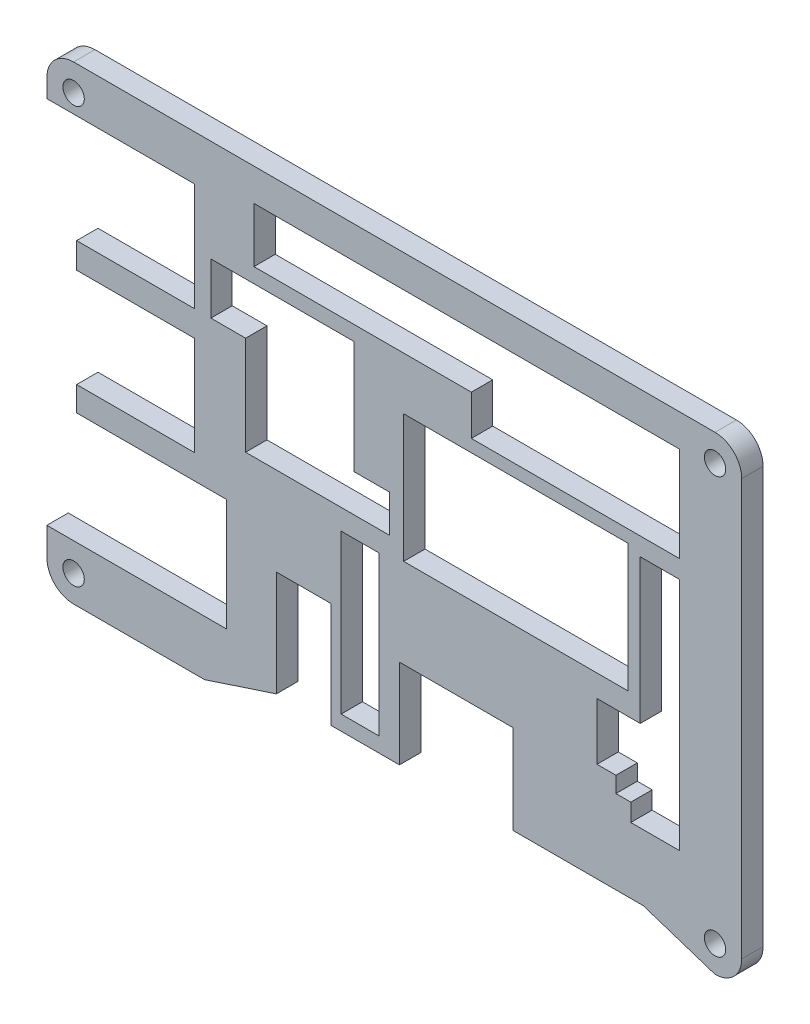
from build123d import *

# Parameters (mm, degrees)
SKETCH2_W           = 5.4034
SKETCH2_H           = 22.6066
SKETCH2_W_2         = 31.9679
SKETCH2_H_2         = 18.2371
BOSS_EXTRUDE1_DEPTH = 3.048
SKETCH3_R           = 1.338245378
CUT_EXTRUDE1_DEPTH  = 4.048
SKETCH4_R           = 1.524
CUT_EXTRUDE2_DEPTH  = 4.048


with BuildPart() as part:
    # Sketch2 → Boss-Extrude1 (new body)
    with BuildSketch(Plane(origin=(0, 0, 8.171752382), x_dir=(-1, 0, 0), z_dir=(0, 0, -1))):
        with BuildLine():
            Line((-23.844892625, -33.084405696), (-34.084892625, -36.451005696))
            ThreePointArc((-34.084892625, -36.451005696), (-36.778969461, -35.335082532), (-37.894892625, -32.641005696))
            Line((-37.894892625, -32.641005696), (-37.894892625, 26.697694304))
            ThreePointArc((-37.894892625, 26.697694304), (-36.778969461, 29.391771141), (-34.084892625, 30.507694304))
            Line((-34.084892625, 30.507694304), (57.404932375, 30.507694304))
            ThreePointArc((57.404932375, 30.507694304), (60.103884597, 29.386886916), (61.214907375, 26.683892153))
            Line((61.214907375, 26.683892153), (61.214907375, 24.068294304))
            Line((61.214907375, 24.068294304), (40.134807375, 24.068294304))
            Line((40.134807375, 24.068294304), (40.134807375, 8.658194304))
            Line((40.134807375, 8.658194304), (56.975007375, 8.658194304))
            Line((56.975007375, 8.658194304), (56.975007375, 4.997894304))
            Line((56.975007375, 4.997894304), (40.134807375, 4.997894304))
            Line((40.134807375, 4.997894304), (40.134807375, -9.121805696))
            Line((40.134807375, -9.121805696), (56.975007375, -9.121805696))
            Line((56.975007375, -9.121805696), (56.975007375, -12.628005696))
            Line((56.975007375, -12.628005696), (35.575007375, -12.628005696))
            Line((35.575007375, -12.628005696), (35.575007375, -28.627805696))
            Line((35.575007375, -28.627805696), (61.214907375, -28.627805696))
            Line((61.214907375, -28.627805696), (61.214907375, -32.613401529))
            ThreePointArc((61.214907375, -32.613401529), (60.108826144, -35.325305244), (57.405007375, -36.451005696))
            Line((57.405007375, -36.451005696), (38.714307375, -36.451005696))
            Line((38.714307375, -36.451005696), (28.474307375, -33.084405696))
            Line((28.474307375, -33.084405696), (28.474307375, -18.034905696))
            Line((28.474307375, -18.034905696), (20.658107375, -18.034905696))
            Line((20.658107375, -18.034905696), (20.658107375, -33.084405696))
            Line((20.658107375, -33.084405696), (10.926407375, -33.084405696))
            Line((10.926407375, -33.084405696), (10.926407375, -20.384405696))
            Line((10.926407375, -20.384405696), (-5.302892625, -20.384405696))
            Line((-5.302892625, -20.384405696), (-5.302892625, -33.084405696))
            Line((-5.302892625, -33.084405696), (-23.844892625, -33.084405696))
        make_face()
        with Locations((16.546707375, -19.663505696)):
            Rectangle(SKETCH2_W, SKETCH2_H, mode=Mode.SUBTRACT)
        Polygon((-29.004892625, -23.698905696), (-22.066892625, -23.698905696), (-22.066892625, -21.185805696), (-19.950892625, -21.185805696), (-19.950892625, -18.920605696), (-17.244692625, -18.920605696), (-17.244692625, -10.792605696), (-23.416892625, -10.792605696), (-23.416892625, 9.801194304), (-29.004892625, 9.801194304), align=None, mode=Mode.SUBTRACT)
        with Locations((-5.654942625, 1.475544304)):
            Rectangle(SKETCH2_W_2, SKETCH2_H_2, mode=Mode.SUBTRACT)
        Polygon((12.361007375, -0.097605696), (17.441007375, -0.097605696), (17.441007375, 15.972394304), (37.825007375, 15.972394304), (37.825007375, 8.658194304), (32.872007375, 8.658194304), (32.872007375, -5.431505696), (12.361007375, -5.431505696), align=None, mode=Mode.SUBTRACT)
        Polygon((0.677107375, 12.372094304), (-29.004794688, 12.372094304), (-29.004892625, 25.896994304), (31.688307375, 25.896994304), (31.688307375, 18.086994304), (0.677107375, 18.086994304), align=None, mode=Mode.SUBTRACT)
    extrude(amount=BOSS_EXTRUDE1_DEPTH)

    # Sketch3 → Cut-Extrude1 (cut, through all)
    with BuildSketch(Plane(origin=(0, 0, 5.123752382), x_dir=(-1, 0, 0), z_dir=(0, 0, -1))):
        with Locations((57.405007375, -32.641005696)):
            Circle(SKETCH3_R)
        with Locations((-34.084892625, -32.641005696)):
            Circle(SKETCH3_R)
        with Locations((-34.084892625, 26.697694304)):
            Circle(SKETCH3_R)
        with Locations((57.404932375, 26.697694304)):
            Circle(SKETCH3_R)
    extrude(amount=-CUT_EXTRUDE1_DEPTH, mode=Mode.SUBTRACT)

    # Sketch4 → Cut-Extrude2 (cut, through all)
    with BuildSketch(Plane(origin=(0, 0, 5.123752382), x_dir=(-1, 0, 0), z_dir=(0, 0, -1))):
        with Locations((-34.084892625, 26.697694304)):
            Circle(SKETCH4_R)
        with Locations((-34.084892625, -32.641005696)):
            Circle(SKETCH4_R)
        with Locations((57.405007375, -32.641005696)):
            Circle(SKETCH4_R)
        with Locations((57.404932375, 26.697694304)):
            Circle(SKETCH4_R)
    extrude(amount=-CUT_EXTRUDE2_DEPTH, mode=Mode.SUBTRACT)


solid = part.part
